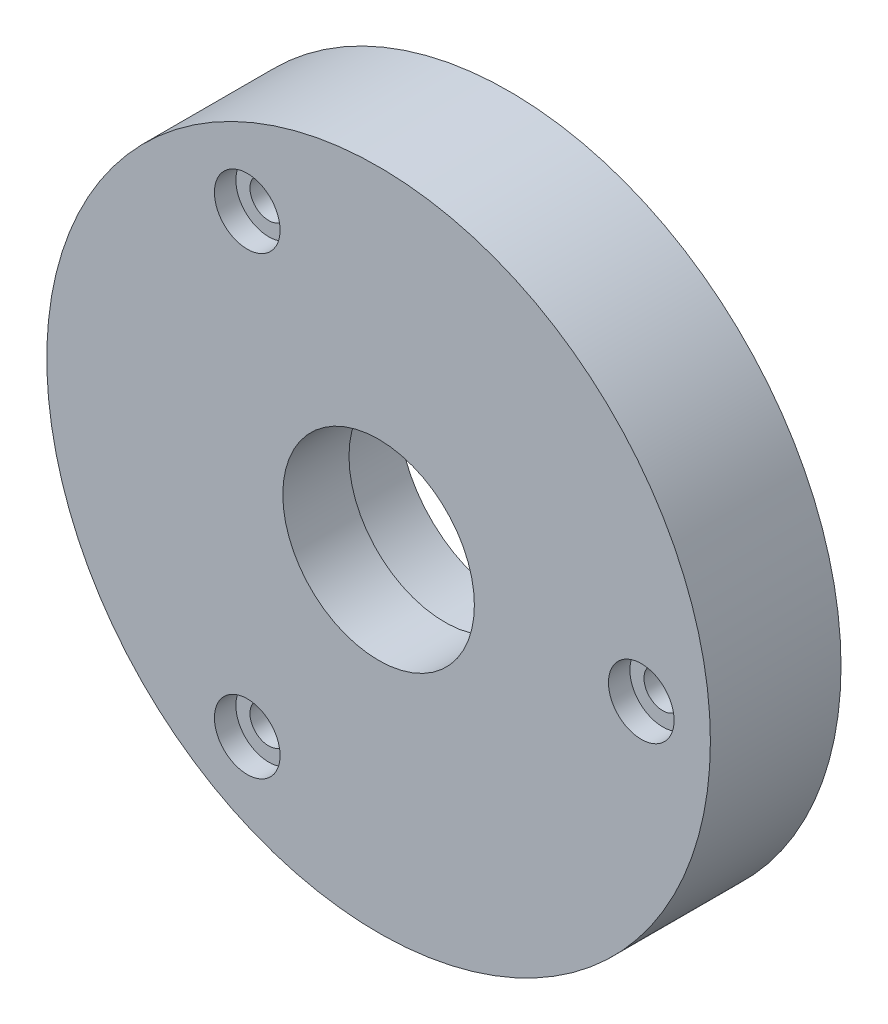
from build123d import *

# Parameters (mm, degrees)
ESQUISSE1_R                                      = 38.1
ESQUISSE1_R_2                                    = 11
BOSS_EXTRU_1_DEPTH                               = 15
ESQUISSE2_R                                      = 12.7
ENL_V_MAT_EXTRU_1_DEPTH                          = 7.4
CHAMBRAGE_POUR_VIS_T_TE_RONDE_BOMB_E_D           = 4.3053
CHAMBRAGE_POUR_VIS_T_TE_RONDE_BOMB_E_DEPTH       = 15
CHAMBRAGE_POUR_VIS_T_TE_RONDE_BOMB_E_CBORE_D     = 7.54126
CHAMBRAGE_POUR_VIS_T_TE_RONDE_BOMB_E_CBORE_DEPTH = 2.4638
CHAMBRAGE_POUR_VIS_T_TE_RONDE_BOMB_E_TIP         = 1.293442612
F_1_8_0_124_TROUS_DE_CENTRAGE1_D                 = 3.1496
F_1_8_0_124_TROUS_DE_CENTRAGE1_DEPTH             = 6.35
F_1_8_0_124_TROUS_DE_CENTRAGE1_TIP               = 0.946235303


with BuildPart() as part:
    # Esquisse1 → Boss.-Extru.1 (new body)
    with BuildSketch(Plane.XY):
        with Locations((23.012291104, 8.435887891)):
            Circle(ESQUISSE1_R)
        with Locations((23.012291104, 8.435887891)):
            Circle(ESQUISSE1_R_2, mode=Mode.SUBTRACT)
    extrude(amount=BOSS_EXTRU_1_DEPTH)

    # Esquisse2 → Enlèv. mat.-Extru.1 (cut)
    with BuildSketch(Plane(origin=(0, 0, 0), x_dir=(-1, 0, 0), z_dir=(0, 0, -1))):
        with Locations((-23.012291104, 8.435887891)):
            Circle(ESQUISSE2_R)
    extrude(amount=-ENL_V_MAT_EXTRU_1_DEPTH, mode=Mode.SUBTRACT)

    # Chambrage pour vis à tête ronde bombée #61
    with Locations(Plane.XY.offset(15)):
        with Locations((7.931041104, 34.557379133), (53.174791104, 8.435887891), (7.931041104, -17.68560335)):
            CounterBoreHole(CHAMBRAGE_POUR_VIS_T_TE_RONDE_BOMB_E_D / 2, CHAMBRAGE_POUR_VIS_T_TE_RONDE_BOMB_E_CBORE_D / 2, CHAMBRAGE_POUR_VIS_T_TE_RONDE_BOMB_E_CBORE_DEPTH, depth=CHAMBRAGE_POUR_VIS_T_TE_RONDE_BOMB_E_DEPTH)
            with Locations((0, 0, -(CHAMBRAGE_POUR_VIS_T_TE_RONDE_BOMB_E_DEPTH + CHAMBRAGE_POUR_VIS_T_TE_RONDE_BOMB_E_TIP / 2))):  # 118° drill point
                Cone(0, CHAMBRAGE_POUR_VIS_T_TE_RONDE_BOMB_E_D / 2, CHAMBRAGE_POUR_VIS_T_TE_RONDE_BOMB_E_TIP, mode=Mode.SUBTRACT)

    # 1/8 (0.124) Trous de centrage1
    with Locations(Plane(origin=(0, 0, 0), x_dir=(-1, 0, 0), z_dir=(0, 0, -1))):
        with Locations((-23.012291104, 40.185887891), (-33.871430655, -21.399352819)):
            Hole(F_1_8_0_124_TROUS_DE_CENTRAGE1_D / 2, depth=F_1_8_0_124_TROUS_DE_CENTRAGE1_DEPTH)
            with Locations((0, 0, -(F_1_8_0_124_TROUS_DE_CENTRAGE1_DEPTH + F_1_8_0_124_TROUS_DE_CENTRAGE1_TIP / 2))):  # 118° drill point
                Cone(0, F_1_8_0_124_TROUS_DE_CENTRAGE1_D / 2, F_1_8_0_124_TROUS_DE_CENTRAGE1_TIP, mode=Mode.SUBTRACT)


solid = part.part
